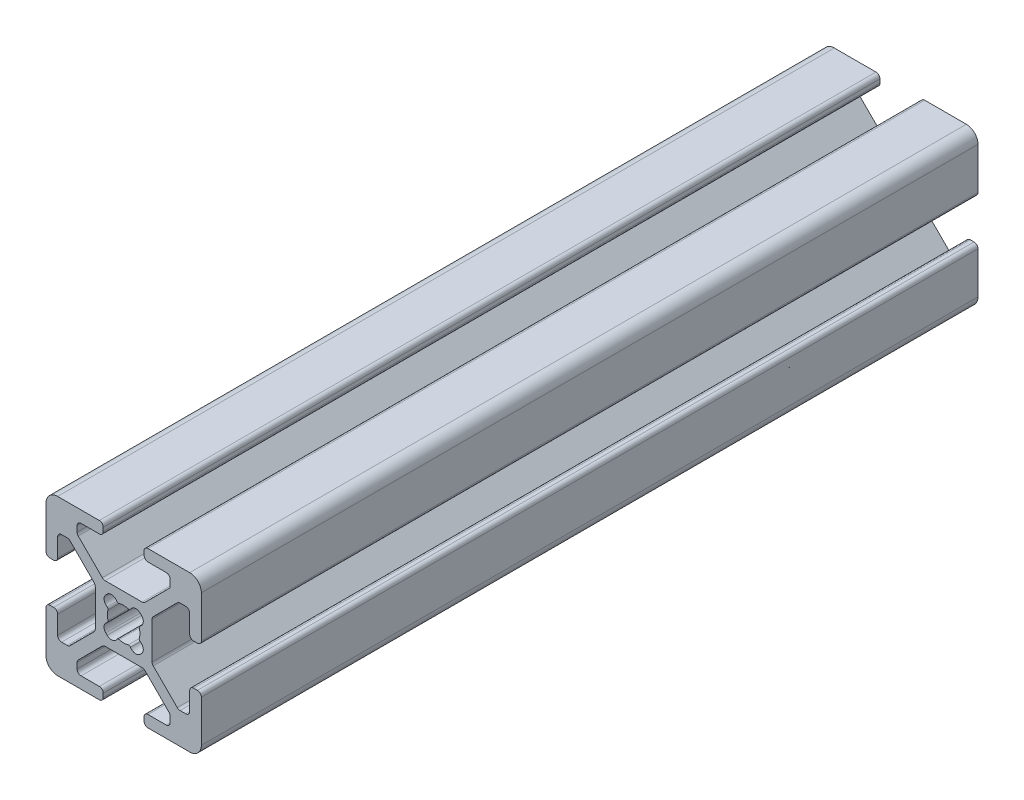
from build123d import *

# Parameters (mm, degrees)
BOSS_EXTRUDE1_DEPTH = 100


with BuildPart() as part:
    # Sketch1 → Boss-Extrude1 (new body)
    with BuildSketch(Plane.XY):
        with BuildLine():
            Line((9.0094, 2.6289), (9.492, 2.6289))
            ThreePointArc((9.492, 2.6289), (9.851210245, 2.777689755), (10, 3.1369))
            Line((10, 3.1369), (10, 8.5014))
            ThreePointArc((10, 8.5014), (9.561070222, 9.561070222), (8.5014, 10))
            Line((8.5014, 10), (3.1369, 10))
            ThreePointArc((3.1369, 10), (2.777689755, 9.851210245), (2.6289, 9.492))
            Line((2.6289, 9.492), (2.6289, 9.0094))
            ThreePointArc((2.6289, 9.0094), (2.777689755, 8.650189755), (3.1369, 8.5014))
            Line((3.1369, 8.5014), (5.4864, 8.5014))
            ThreePointArc((5.4864, 8.5014), (5.845610245, 8.352610245), (5.9944, 7.9934))
            Line((5.9944, 7.9934), (5.9944, 7.264490712))
            ThreePointArc((5.9944, 7.264490712), (5.955730803, 7.070087528), (5.845610245, 6.905280467))
            Line((5.845610245, 6.905280467), (2.747686782, 3.807357004))
            ThreePointArc((2.747686782, 3.807357004), (2.582879721, 3.697236446), (2.388476537, 3.658567249))
            Line((2.388476537, 3.658567249), (-2.388476537, 3.658567249))
            ThreePointArc((-2.388476537, 3.658567249), (-2.582879721, 3.697236446), (-2.747686782, 3.807357004))
            Line((-2.747686782, 3.807357004), (-5.845610245, 6.905280467))
            ThreePointArc((-5.845610245, 6.905280467), (-5.955730803, 7.070087528), (-5.9944, 7.264490712))
            Line((-5.9944, 7.264490712), (-5.9944, 7.9934))
            ThreePointArc((-5.9944, 7.9934), (-5.845610245, 8.352610245), (-5.4864, 8.5014))
            Line((-5.4864, 8.5014), (-3.1369, 8.5014))
            ThreePointArc((-3.1369, 8.5014), (-2.777689755, 8.650189755), (-2.6289, 9.0094))
            Line((-2.6289, 9.0094), (-2.6289, 9.492))
            ThreePointArc((-2.6289, 9.492), (-2.777689755, 9.851210245), (-3.1369, 10))
            Line((-3.1369, 10), (-8.5014, 10))
            ThreePointArc((-8.5014, 10), (-9.561070222, 9.561070222), (-10, 8.5014))
            Line((-10, 8.5014), (-10, 3.1369))
            ThreePointArc((-10, 3.1369), (-9.851210245, 2.777689755), (-9.492, 2.6289))
            Line((-9.492, 2.6289), (-9.0094, 2.6289))
            ThreePointArc((-9.0094, 2.6289), (-8.650189755, 2.777689755), (-8.5014, 3.1369))
            Line((-8.5014, 3.1369), (-8.5014, 5.4864))
            ThreePointArc((-8.5014, 5.4864), (-8.352610245, 5.845610245), (-7.9934, 5.9944))
            Line((-7.9934, 5.9944), (-7.264490712, 5.9944))
            ThreePointArc((-7.264490712, 5.9944), (-7.070087528, 5.955730803), (-6.905280467, 5.845610245))
            Line((-6.905280467, 5.845610245), (-3.807357004, 2.747686782))
            ThreePointArc((-3.807357004, 2.747686782), (-3.697236446, 2.582879721), (-3.658567249, 2.388476537))
            Line((-3.658567249, 2.388476537), (-3.658567249, -2.388476537))
            ThreePointArc((-3.658567249, -2.388476537), (-3.697236446, -2.582879721), (-3.807357004, -2.747686782))
            Line((-3.807357004, -2.747686782), (-6.905280467, -5.845610245))
            ThreePointArc((-6.905280467, -5.845610245), (-7.070087528, -5.955730803), (-7.264490712, -5.9944))
            Line((-7.264490712, -5.9944), (-7.9934, -5.9944))
            ThreePointArc((-7.9934, -5.9944), (-8.352610245, -5.845610245), (-8.5014, -5.4864))
            Line((-8.5014, -5.4864), (-8.5014, -3.1369))
            ThreePointArc((-8.5014, -3.1369), (-8.650189755, -2.777689755), (-9.0094, -2.6289))
            Line((-9.0094, -2.6289), (-9.492, -2.6289))
            ThreePointArc((-9.492, -2.6289), (-9.851210245, -2.777689755), (-10, -3.1369))
            Line((-10, -3.1369), (-10, -8.5014))
            ThreePointArc((-10, -8.5014), (-9.561070222, -9.561070222), (-8.5014, -10))
            Line((-8.5014, -10), (-3.1369, -10))
            ThreePointArc((-3.1369, -10), (-2.777689755, -9.851210245), (-2.6289, -9.492))
            Line((-2.6289, -9.492), (-2.6289, -9.0094))
            ThreePointArc((-2.6289, -9.0094), (-2.777689755, -8.650189755), (-3.1369, -8.5014))
            Line((-3.1369, -8.5014), (-5.4864, -8.5014))
            ThreePointArc((-5.4864, -8.5014), (-5.845610245, -8.352610245), (-5.9944, -7.9934))
            Line((-5.9944, -7.9934), (-5.9944, -7.264490712))
            ThreePointArc((-5.9944, -7.264490712), (-5.955730803, -7.070087528), (-5.845610245, -6.905280467))
            Line((-5.845610245, -6.905280467), (-2.747686782, -3.807357004))
            ThreePointArc((-2.747686782, -3.807357004), (-2.582879721, -3.697236446), (-2.388476537, -3.658567249))
            Line((-2.388476537, -3.658567249), (2.388476537, -3.658567249))
            ThreePointArc((2.388476537, -3.658567249), (2.582879721, -3.697236446), (2.747686782, -3.807357004))
            Line((2.747686782, -3.807357004), (5.845610245, -6.905280467))
            ThreePointArc((5.845610245, -6.905280467), (5.955730803, -7.070087528), (5.9944, -7.264490712))
            Line((5.9944, -7.264490712), (5.9944, -7.9934))
            ThreePointArc((5.9944, -7.9934), (5.845610245, -8.352610245), (5.4864, -8.5014))
            Line((5.4864, -8.5014), (3.1369, -8.5014))
            ThreePointArc((3.1369, -8.5014), (2.777689755, -8.650189755), (2.6289, -9.0094))
            Line((2.6289, -9.0094), (2.6289, -9.492))
            ThreePointArc((2.6289, -9.492), (2.777689755, -9.851210245), (3.1369, -10))
            Line((3.1369, -10), (8.5014, -10))
            ThreePointArc((8.5014, -10), (9.561070222, -9.561070222), (10, -8.5014))
            Line((10, -8.5014), (10, -3.1369))
            ThreePointArc((10, -3.1369), (9.851210245, -2.777689755), (9.492, -2.6289))
            Line((9.492, -2.6289), (9.0094, -2.6289))
            ThreePointArc((9.0094, -2.6289), (8.650189755, -2.777689755), (8.5014, -3.1369))
            Line((8.5014, -3.1369), (8.5014, -5.4864))
            ThreePointArc((8.5014, -5.4864), (8.352610245, -5.845610245), (7.9934, -5.9944))
            Line((7.9934, -5.9944), (7.264490712, -5.9944))
            ThreePointArc((7.264490712, -5.9944), (7.070087528, -5.955730803), (6.905280467, -5.845610245))
            Line((6.905280467, -5.845610245), (3.807357004, -2.747686782))
            ThreePointArc((3.807357004, -2.747686782), (3.697236446, -2.582879721), (3.658567249, -2.388476537))
            Line((3.658567249, -2.388476537), (3.658567249, 2.388476537))
            ThreePointArc((3.658567249, 2.388476537), (3.697236446, 2.582879721), (3.807357004, 2.747686782))
            Line((3.807357004, 2.747686782), (6.905280467, 5.845610245))
            ThreePointArc((6.905280467, 5.845610245), (7.070087528, 5.955730803), (7.264490712, 5.9944))
            Line((7.264490712, 5.9944), (7.9934, 5.9944))
            ThreePointArc((7.9934, 5.9944), (8.352610245, 5.845610245), (8.5014, 5.4864))
            Line((8.5014, 5.4864), (8.5014, 3.1369))
            ThreePointArc((8.5014, 3.1369), (8.650189755, 2.777689755), (9.0094, 2.6289))
        make_face()
        with BuildLine():
            Line((-2.296558466, 2.121727546), (-2.121727546, 2.296558466))
            ThreePointArc((-2.121727546, 2.296558466), (-1.459775814, 2.520126613), (-0.880635441, 2.129282347))
            ThreePointArc((-0.880635441, 2.129282347), (-0.755121693, 2.019456424), (-0.588548999, 2.011151493))
            ThreePointArc((-0.588548999, 2.011151493), (0, 2.0955), (0.588548999, 2.011151493))
            ThreePointArc((0.588548999, 2.011151493), (0.755121693, 2.019456424), (0.880635441, 2.129282347))
            ThreePointArc((0.880635441, 2.129282347), (1.459775814, 2.520126613), (2.121727546, 2.296558466))
            Line((2.121727546, 2.296558466), (2.296558466, 2.121727546))
            ThreePointArc((2.296558466, 2.121727546), (2.520126613, 1.459775814), (2.129282347, 0.880635441))
            ThreePointArc((2.129282347, 0.880635441), (2.019456424, 0.755121693), (2.011151493, 0.588548999))
            ThreePointArc((2.011151493, 0.588548999), (2.0955, 0), (2.011151493, -0.588548999))
            ThreePointArc((2.011151493, -0.588548999), (2.019456424, -0.755121693), (2.129282347, -0.880635441))
            ThreePointArc((2.129282347, -0.880635441), (2.520126613, -1.459775814), (2.296558466, -2.121727546))
            Line((2.296558466, -2.121727546), (2.121727546, -2.296558466))
            ThreePointArc((2.121727546, -2.296558466), (1.459775814, -2.520126613), (0.880635441, -2.129282347))
            ThreePointArc((0.880635441, -2.129282347), (0.755121693, -2.019456424), (0.588548999, -2.011151493))
            ThreePointArc((0.588548999, -2.011151493), (0, -2.0955), (-0.588548999, -2.011151493))
            ThreePointArc((-0.588548999, -2.011151493), (-0.755121693, -2.019456424), (-0.880635441, -2.129282347))
            ThreePointArc((-0.880635441, -2.129282347), (-1.459775814, -2.520126613), (-2.121727546, -2.296558466))
            Line((-2.121727546, -2.296558466), (-2.296558466, -2.121727546))
            ThreePointArc((-2.296558466, -2.121727546), (-2.520126613, -1.459775814), (-2.129282347, -0.880635441))
            ThreePointArc((-2.129282347, -0.880635441), (-2.019456424, -0.755121693), (-2.011151493, -0.588548999))
            ThreePointArc((-2.011151493, -0.588548999), (-2.0955, 0), (-2.011151493, 0.588548999))
            ThreePointArc((-2.011151493, 0.588548999), (-2.019456424, 0.755121693), (-2.129282347, 0.880635441))
            ThreePointArc((-2.129282347, 0.880635441), (-2.520126613, 1.459775814), (-2.296558466, 2.121727546))
        make_face(mode=Mode.SUBTRACT)
    extrude(amount=BOSS_EXTRUDE1_DEPTH)


solid = part.part
